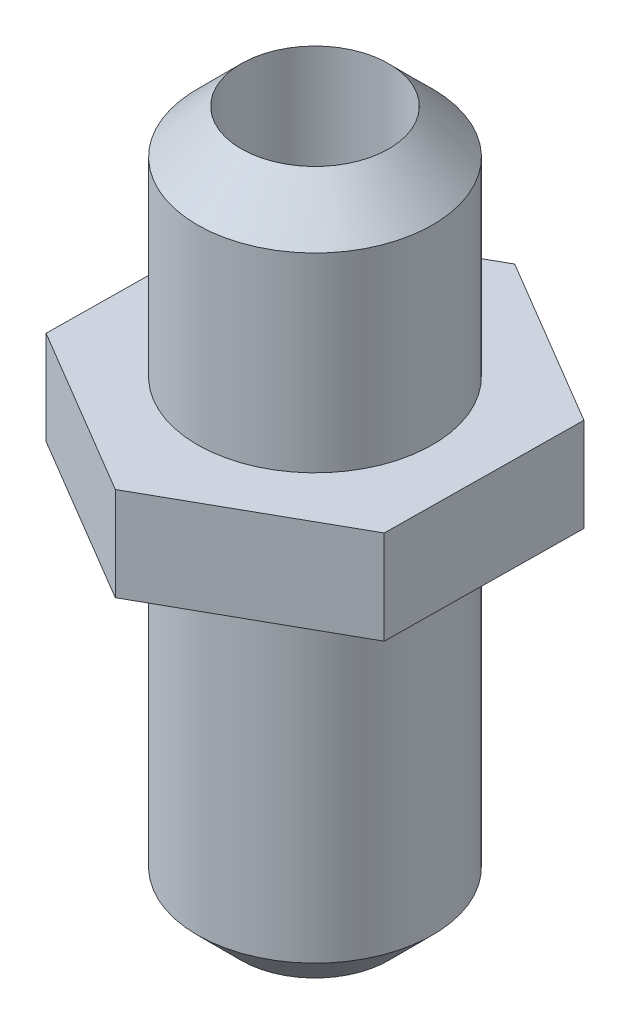
from build123d import *

# Parameters (mm, degrees)
BOSS_EXTRUDE1_DEPTH = 5.08
SKETCH1_4_R         = 6.38048
BOSS_EXTRUDE2_DEPTH = 17.78
BOSS_EXTRUDE3_START = -20.32
SKETCH1_5_R         = 6.38048
BOSS_EXTRUDE3_DEPTH = 20.32
SKETCH3_R           = 4.00047968
CUT_EXTRUDE1_DEPTH  = 50.292
CHAMFER1_SIZE       = 2.38
CHAMFER2_SIZE       = 2.38


with BuildPart() as part:
    # Sketch1 → Boss-Extrude1 (new body)
    with BuildSketch(Plane(origin=(0, 0, 0), x_dir=(1, 0, 0), z_dir=(0, 1, 0))):
        Polygon((-0.121280128, -10.704541675), (9.209764962, -5.457302509), (9.33104509, 5.247239165), (0.121280128, 10.704541675), (-9.209764962, 5.457302509), (-9.33104509, -5.247239165), align=None)
    extrude(amount=BOSS_EXTRUDE1_DEPTH)

    # Sketch1_4 → Boss-Extrude2 (add)
    with BuildSketch(Plane(origin=(0, 0, 0), x_dir=(1, 0, 0), z_dir=(0, 1, 0))):
        Circle(SKETCH1_4_R)
    extrude(amount=BOSS_EXTRUDE2_DEPTH)

    # Sketch1_5 → Boss-Extrude3 (add)
    with BuildSketch(Plane(origin=(0, 0, 0), x_dir=(1, 0, 0), z_dir=(0, 1, 0)).offset(BOSS_EXTRUDE3_START)):
        Circle(SKETCH1_5_R)
    extrude(amount=BOSS_EXTRUDE3_DEPTH)

    # Sketch3 → Cut-Extrude1 (cut)
    with BuildSketch(Plane(origin=(0, 17.78, 0), x_dir=(1, 0, 0), z_dir=(0, 1, 0))):
        Circle(SKETCH3_R)
    extrude(amount=-CUT_EXTRUDE1_DEPTH, mode=Mode.SUBTRACT)

    # Chamfer1
    chamfer1_edges = [part.edges().sort_by_distance(p)[0] for p in [
        (-6.38048, 17.78, 0),
    ]]
    chamfer(chamfer1_edges, length=CHAMFER1_SIZE)

    # Chamfer2
    chamfer2_edges = [part.edges().sort_by_distance(p)[0] for p in [
        (-6.38048, -20.32, 0),
    ]]
    chamfer(chamfer2_edges, length=CHAMFER2_SIZE)


solid = part.part
